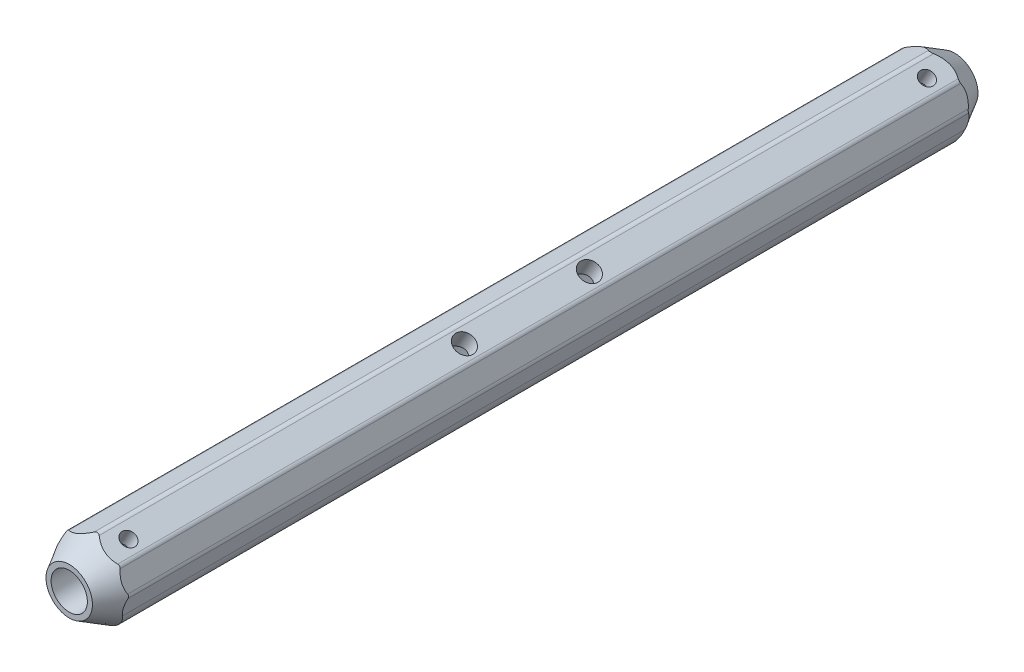
from build123d import *

# Parameters (mm, degrees)
SKETCH1_R                    = 6.25
BOSS_EXTRUDE1_DEPTH          = 152.5
FILLET1_R                    = 2
M8_TAPPED_HOLE1_D            = 6.8
M8_TAPPED_HOLE1_DEPTH        = 22.25
M8_TAPPED_HOLE1_TIP          = 2.042926105
M8_TAPPED_HOLE2_D            = 6.8
M8_TAPPED_HOLE2_DEPTH        = 15
M8_TAPPED_HOLE2_TIP          = 2.042926105
F_3_0_3_DIAMETER_HOLE1_D     = 3
F_3_0_3_DIAMETER_HOLE1_DEPTH = 10
F_3_0_3_DIAMETER_HOLE1_TIP   = 0.901290929
M6_TAPPED_HOLE1_D            = 5
M6_TAPPED_HOLE1_DEPTH        = 14
M6_TAPPED_HOLE1_TIP          = 1.502151548


with BuildPart() as part:
    # Sketch1 → Boss-Extrude1 (new body, symmetric)
    with BuildSketch(Plane.XY):
        with BuildLine():
            Line((-7.626973173, -9.452971446), (-3.742747441, -11.695530218))
            ThreePointArc((-3.742747441, -11.695530218), (5.084086883, -12.274071506), (10.916510822, -5.623466631))
            Line((10.916510822, -5.623466631), (12.645396641, 0.828823085))
            Line((12.645396641, 0.828823085), (9.527712139, 8.355579292))
            Line((9.527712139, 8.355579292), (0.659782978, 13.47548058))
            Line((0.659782978, 13.47548058), (-9.518978128, 9.259299682))
            Line((-9.518978128, 9.259299682), (-11.82030561, 0.670628594))
            ThreePointArc((-11.82030561, 0.670628594), (-11.441888966, -5.102893703), (-7.626973173, -9.452971446))
        make_face()
        Circle(SKETCH1_R, mode=Mode.SUBTRACT)
    extrude(amount=BOSS_EXTRUDE1_DEPTH, both=True)

    # Fillet1
    fillet1_edges = [part.edges().sort_by_distance(p)[0] for p in [
        (0.659782978, 13.47548058, 0),
        (9.527712139, 8.355579292, 0),
        (12.645396641, 0.828823085, 0),
        (-9.518978128, 9.259299682, 0),
    ]]
    fillet(fillet1_edges, radius=FILLET1_R)

    # Sketch2 → Cut-Revolve2 (revolve, cut)
    with BuildSketch(Plane(origin=(0, 0, 0), x_dir=(1, 0, 0), z_dir=(0, 1, 0)), mode=Mode.PRIVATE) as cut_revolve2_sk:
        Polygon((-8, 152.5), (-20, 152.5), (-20, 131.715390309), align=None)
        Polygon((-8, -152.5), (-20, -152.5), (-20, -131.715390309), align=None)
    revolve(cut_revolve2_sk.sketch.rotate(Axis((0, 0, -164.78478065), (0, 0, 1)), 180.795069983), axis=Axis((0, 0, -164.78478065), (0, 0, 1)), mode=Mode.SUBTRACT)  # turned: the seam where the file's is

    # M8 Tapped Hole1
    with Locations(Plane(origin=(8, 13.856406461, 0), x_dir=(-0.866025404, 0.5, 0), z_dir=(0.5, 0.866025404, 0))):
        with Locations((1, 21.524910819), (1, -21.524910819)):
            Hole(M8_TAPPED_HOLE1_D / 2, depth=M8_TAPPED_HOLE1_DEPTH)
            with Locations((0, 0, -(M8_TAPPED_HOLE1_DEPTH + M8_TAPPED_HOLE1_TIP / 2))):  # 118° drill point
                Cone(0, M8_TAPPED_HOLE1_D / 2, M8_TAPPED_HOLE1_TIP, mode=Mode.SUBTRACT)

    # M8 Tapped Hole2
    with Locations(Plane(origin=(-11.196152423, 3, 0), x_dir=(0, 0, 1), z_dir=(-0.965925826, 0.258819045, 0))):
        with Locations((-123, 2), (123, 2)):
            Hole(M8_TAPPED_HOLE2_D / 2, depth=M8_TAPPED_HOLE2_DEPTH)
            with Locations((0, 0, -(M8_TAPPED_HOLE2_DEPTH + M8_TAPPED_HOLE2_TIP / 2))):  # 118° drill point
                Cone(0, M8_TAPPED_HOLE2_D / 2, M8_TAPPED_HOLE2_TIP, mode=Mode.SUBTRACT)

    # Ø3.0 (3) Diameter Hole1
    with Locations(Plane(origin=(-11.196152423, 3, 0), x_dir=(0, 0, 1), z_dir=(-0.965925826, 0.258819045, 0))):
        with Locations((115.085456425, -0.5), (-115.085456425, -0.5)):
            Hole(F_3_0_3_DIAMETER_HOLE1_D / 2, depth=F_3_0_3_DIAMETER_HOLE1_DEPTH)
            with Locations((0, 0, -(F_3_0_3_DIAMETER_HOLE1_DEPTH + F_3_0_3_DIAMETER_HOLE1_TIP / 2))):  # 118° drill point
                Cone(0, F_3_0_3_DIAMETER_HOLE1_D / 2, F_3_0_3_DIAMETER_HOLE1_TIP, mode=Mode.SUBTRACT)

    # M6 Tapped Hole1
    with Locations(Plane(origin=(6, 10.392304845, 0), x_dir=(0.866025404, -0.5, 0), z_dir=(0.5, 0.866025404, 0))):
        with Locations((-0.686204209, -137.5), (-0.686204209, 137.5)):
            Hole(M6_TAPPED_HOLE1_D / 2, depth=M6_TAPPED_HOLE1_DEPTH)
            with Locations((0, 0, -(M6_TAPPED_HOLE1_DEPTH + M6_TAPPED_HOLE1_TIP / 2))):  # 118° drill point
                Cone(0, M6_TAPPED_HOLE1_D / 2, M6_TAPPED_HOLE1_TIP, mode=Mode.SUBTRACT)


solid = part.part
